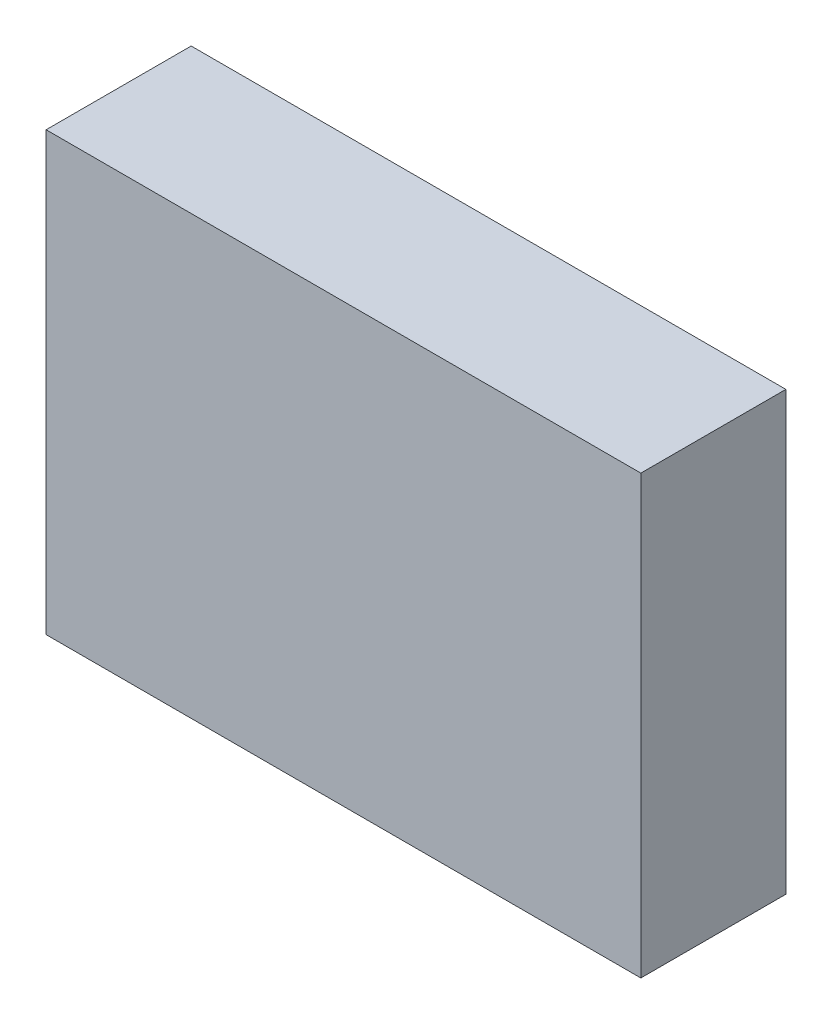
from build123d import *

# Parameters (mm, degrees)
SKETCH1_W               = 7.1755
SKETCH1_H               = 5.27558
COMPONENT_OUTLINE_DEPTH = 1.75006


with BuildPart() as part:
    # Sketch1 → Component_Outline (new body)
    with BuildSketch(Plane.XY):
        Rectangle(SKETCH1_W, SKETCH1_H)
    extrude(amount=COMPONENT_OUTLINE_DEPTH)


solid = part.part
